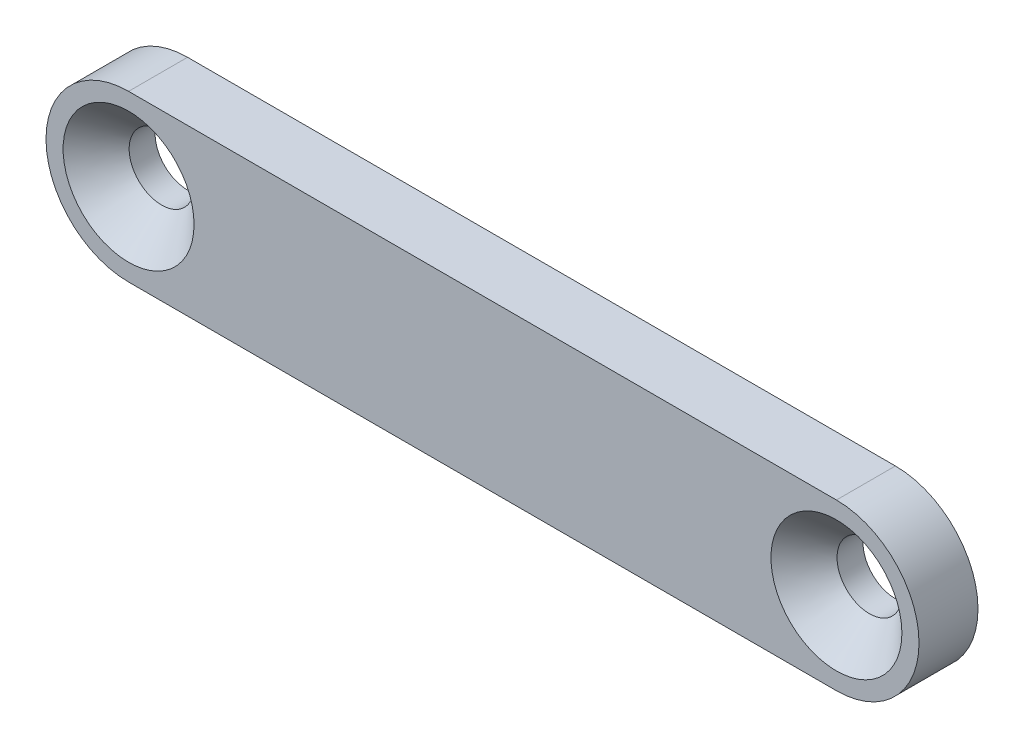
from build123d import *

# Parameters (mm, degrees)
ESQUISSE1_R        = 2.75
BOSS_EXTRU_1_DEPTH = 5
CHANFREIN1_SIZE    = 2.8


with BuildPart() as part:
    # Esquisse1 → Boss.-Extru.1 (new body)
    with BuildSketch(Plane.XY):
        with BuildLine():
            Line((0, 7), (60, 7))
            ThreePointArc((60, 7), (67, 0), (60, -7))
            Line((60, -7), (0, -7))
            ThreePointArc((0, -7), (-7, 0), (0, 7))
        make_face()
        with Locations((60, 0)):
            Circle(ESQUISSE1_R, mode=Mode.SUBTRACT)
        Circle(ESQUISSE1_R, mode=Mode.SUBTRACT)
    extrude(amount=BOSS_EXTRU_1_DEPTH)

    # Chanfrein1
    chanfrein1_edges = [part.edges().sort_by_distance(p)[0] for p in [
        (57.25, 0, 5),
        (-2.75, 0, 5),
    ]]
    chamfer(chanfrein1_edges, length=CHANFREIN1_SIZE)


solid = part.part
